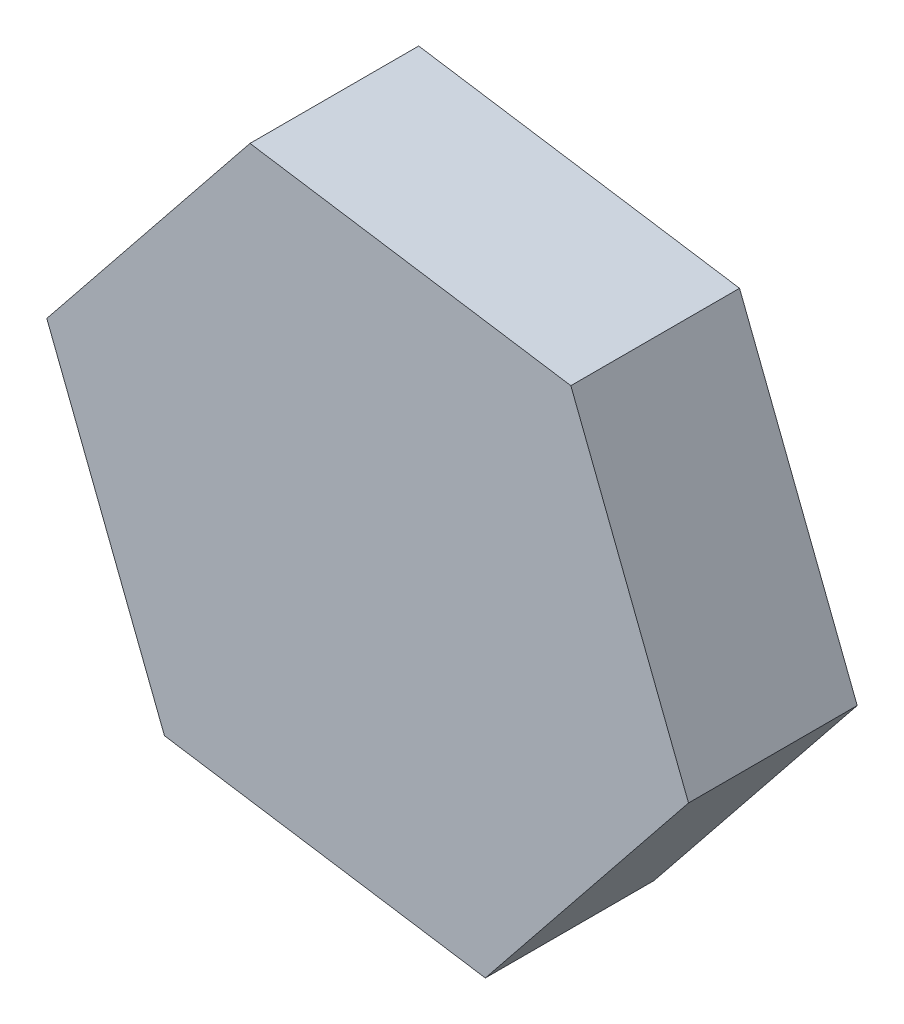
from build123d import *

# Parameters (mm, degrees)
SALIENTE_EXTRUIR3_DEPTH = 3


with BuildPart() as part:
    # Croquis1 → Saliente-Extruir3 (new body)
    with BuildSketch(Plane.XY):
        Polygon((-54.386636348, 4.299863782), (-50.772905222, 8.802560828), (-52.865489687, 14.183492308), (-58.571805277, 15.061726742), (-62.185536402, 10.559029696), (-60.092951938, 5.178098216), align=None)
    extrude(amount=SALIENTE_EXTRUIR3_DEPTH)


solid = part.part
